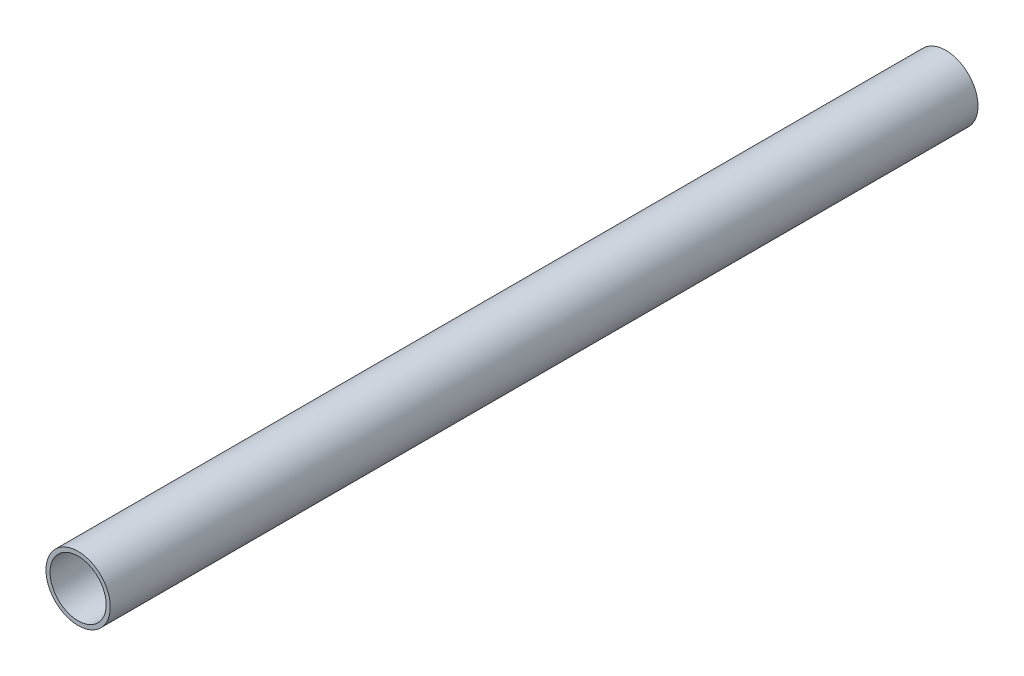
from build123d import *

# Parameters (mm, degrees)
SKETCH1_R           = 18.923
SKETCH1_R_2         = 16.51
BOSS_EXTRUDE1_DEPTH = 510.54


with BuildPart() as part:
    # Sketch1 → Boss-Extrude1 (new body)
    with BuildSketch(Plane.XY):
        Circle(SKETCH1_R)
        Circle(SKETCH1_R_2, mode=Mode.SUBTRACT)
    extrude(amount=BOSS_EXTRUDE1_DEPTH)


solid = part.part
